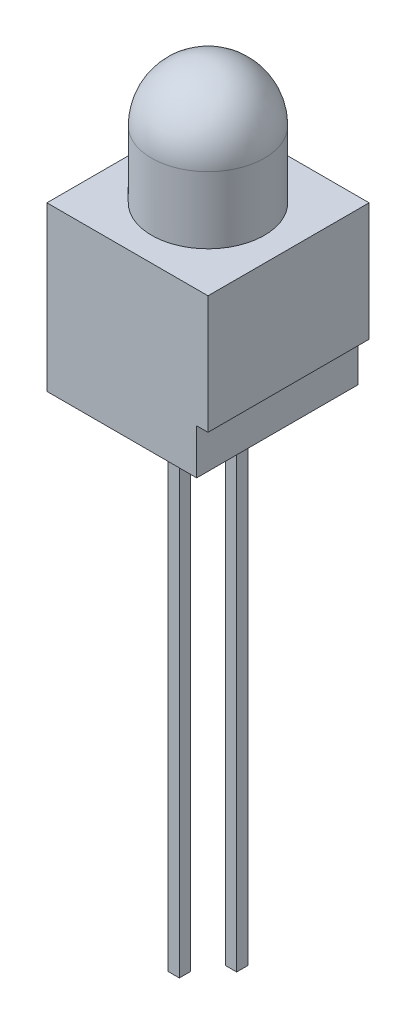
from build123d import *

# Parameters (mm, degrees)
EXTRUDE1_DEPTH     = 3.57
SKETCH1_5_W        = 0.5
SKETCH1_5_H        = 22.9
SKETCH1_5_H_2      = 21.4
EXTRUDE2_DEPTH     = 0.25
SKETCH2_W          = 0.025316456
SKETCH2_H          = 0.026582279
CUT_EXTRUDE1_DEPTH = 0.01


with BuildPart() as part:
    # Sketch1 → Extrude1 (new body, symmetric)
    with BuildSketch(Plane.XY):
        Polygon((0, 0), (-3.57, 0), (-3.57, -7.24), (-1.52, -7.24), (-1.02, -7.24), (1.02, -7.24), (1.52, -7.24), (3.07, -7.24), (3.07, -5.24), (3.57, -5.24), (3.57, 0), (2.5, 0), align=None)
    extrude(amount=EXTRUDE1_DEPTH, both=True)

    # Sketch1_4 → Revolve1 (revolve)
    with BuildSketch(Plane.XY, mode=Mode.PRIVATE) as revolve1_sk:
        with BuildLine():
            Line((0, 5.46), (0, 0))
            Line((0, 0), (2.5, 0))
            Line((2.5, 0), (2.5, 2.96))
            ThreePointArc((2.5, 2.96), (1.767766953, 4.727766953), (0, 5.46))
        make_face()
    revolve(revolve1_sk.sketch.rotate(Axis((0, 0, 0), (0, 1, 0)), 180), axis=Axis((0, 0, 0), (0, 1, 0)))  # turned: the seam where the file's is

    # Sketch1_5 → Extrude2 (add, symmetric)
    with BuildSketch(Plane.XY):
        with Locations((-1.27, -18.69)):
            Rectangle(SKETCH1_5_W, SKETCH1_5_H)
        with Locations((1.27, -17.94)):
            Rectangle(SKETCH1_5_W, SKETCH1_5_H_2)
    extrude(amount=EXTRUDE2_DEPTH, both=True)

    # Sketch2 → Cut-Extrude1 (cut)
    with BuildSketch(Plane.XZ.offset(7.24)):
        Polygon((-0.822151899, -2.422773337), (-0.845609177, -2.497456881), (-0.870352057, -2.497456881), (-0.886768196, -2.447120647), (-0.902294304, -2.497456881), (-0.928026108, -2.497456881), (-0.951265823, -2.422773337), (-0.926087816, -2.422773337), (-0.913093354, -2.474256723), (-0.896677215, -2.422773337), (-0.875178006, -2.422773337), (-0.858860759, -2.474256723), (-0.846044304, -2.422773337), align=None)
        Polygon((-0.687974684, -2.422773337), (-0.711431962, -2.497456881), (-0.736174842, -2.497456881), (-0.752590981, -2.447120647), (-0.768117089, -2.497456881), (-0.793848892, -2.497456881), (-0.817088608, -2.422773337), (-0.791910601, -2.422773337), (-0.778916139, -2.474256723), (-0.7625, -2.422773337), (-0.741000791, -2.422773337), (-0.724683544, -2.474256723), (-0.711867089, -2.422773337), align=None)
        Polygon((-0.553797468, -2.422773337), (-0.577254747, -2.497456881), (-0.601997627, -2.497456881), (-0.618413766, -2.447120647), (-0.633939873, -2.497456881), (-0.659671677, -2.497456881), (-0.682911392, -2.422773337), (-0.657733386, -2.422773337), (-0.644738924, -2.474256723), (-0.628322785, -2.422773337), (-0.606823576, -2.422773337), (-0.590506329, -2.474256723), (-0.577689873, -2.422773337), align=None)
        with Locations((-0.525949367, -2.484165742)):
            Rectangle(SKETCH2_W, SKETCH2_H)
        with BuildLine():
            add(Edge.make_bspline(
                [(-0.409493671, -2.466285995), (-0.40953016, -2.467508136), (-0.409601812, -2.469908014), (-0.41021153, -2.473415593), (-0.411205016, -2.476740298), (-0.412579134, -2.479902958), (-0.414367936, -2.482881577), (-0.416577526, -2.485661854), (-0.419141939, -2.488296654), (-0.422108149, -2.490702784), (-0.425388259, -2.492907161), (-0.428985835, -2.49480416), (-0.432864539, -2.496400643), (-0.437013125, -2.497739194), (-0.441459564, -2.498727775), (-0.446177094, -2.49945172), (-0.451170512, -2.49992505), (-0.45459409, -2.499967016), (-0.456348892, -2.499988527)],
                knots=[0, 0, 0, 0, 0.907352243, 1.781736951, 2.63548328, 3.47985091, 4.336556021, 5.208523475, 6.112432747, 7.062451073, 8.040435374, 9.043840564, 10.077958095, 11.152835584, 12.277940427, 13.457536469, 14.696825396, 16, 16, 16, 16], degree=3))
            add(Edge.make_bspline(
                [(-0.456348892, -2.499988527), (-0.458367148, -2.499964455), (-0.46227633, -2.49991783), (-0.467939855, -2.499489231), (-0.473207892, -2.498843092), (-0.478103607, -2.49787655), (-0.482708206, -2.496675785), (-0.487141474, -2.495384493), (-0.491422786, -2.493920078), (-0.494195876, -2.49281992), (-0.49556962, -2.492274919)],
                knots=[0, 0, 0, 0, 1.203215828, 2.33052265, 3.384689099, 4.366106119, 5.303329643, 6.221311756, 7.118865988, 8, 8, 8, 8], degree=3))
            Line((-0.49556962, -2.492274919), (-0.49556962, -2.468342957))
            Line((-0.49556962, -2.468342957), (-0.492721519, -2.468342957))
            add(Edge.make_bspline(
                [(-0.492721519, -2.468342957), (-0.491356205, -2.469424412), (-0.488633592, -2.471580973), (-0.484200359, -2.474343578), (-0.479552713, -2.476745741), (-0.474707243, -2.478719743), (-0.469810398, -2.480306067), (-0.46493502, -2.481399594), (-0.460169433, -2.482146943), (-0.457010864, -2.48222745), (-0.455458861, -2.482267008)],
                knots=[0, 0, 0, 0, 1.030622468, 2.055194264, 3.087043286, 4.125157485, 5.149848264, 6.130935704, 7.081611712, 8, 8, 8, 8], degree=3))
            add(Edge.make_bspline(
                [(-0.455458861, -2.482267008), (-0.455030085, -2.482266084), (-0.454112108, -2.482264107), (-0.452650581, -2.482136379), (-0.45099877, -2.482040803), (-0.449226261, -2.481833619), (-0.447429535, -2.481611758), (-0.445767134, -2.481236833), (-0.444257539, -2.480871966), (-0.443351018, -2.480503968), (-0.442919304, -2.480328716)],
                knots=[0, 0, 0, 0, 0.806402781, 1.726445712, 2.758724871, 3.919014682, 5.083870887, 6.16165551, 7.124521387, 8, 8, 8, 8], degree=3))
            add(Edge.make_bspline(
                [(-0.442919304, -2.480328716), (-0.442439741, -2.480100575), (-0.441497298, -2.479652227), (-0.440203698, -2.478841909), (-0.439036018, -2.477958444), (-0.437978647, -2.476993513), (-0.437104366, -2.475827763), (-0.436480499, -2.47441909), (-0.436135606, -2.472770072), (-0.436096583, -2.471594869), (-0.436075949, -2.470973495)],
                knots=[0, 0, 0, 0, 1.024747072, 2.013846092, 2.940605744, 3.850156746, 4.769278501, 5.73222711, 6.800942666, 8, 8, 8, 8], degree=3))
            add(Edge.make_bspline(
                [(-0.436075949, -2.470973495), (-0.436107794, -2.470427858), (-0.43617041, -2.469354974), (-0.436747603, -2.467819859), (-0.437657041, -2.466410691), (-0.438938631, -2.465141916), (-0.440531807, -2.463992383), (-0.442474191, -2.463010077), (-0.444724312, -2.46213689), (-0.446368382, -2.461718912), (-0.447231013, -2.461499602)],
                knots=[0, 0, 0, 0, 0.82557554, 1.623324704, 2.456147571, 3.35491006, 4.343819762, 5.427079081, 6.650009487, 8, 8, 8, 8], degree=3))
            add(Edge.make_bspline(
                [(-0.447231013, -2.461499602), (-0.449199639, -2.461051362), (-0.453238649, -2.460131712), (-0.459388473, -2.458992958), (-0.465516824, -2.457718098), (-0.469469591, -2.456511455), (-0.471400316, -2.455922071)],
                knots=[0, 0, 0, 0, 0.976100998, 2.002656142, 3.024398856, 4, 4, 4, 4], degree=3))
            add(Edge.make_bspline(
                [(-0.471400316, -2.455922071), (-0.472438835, -2.455569081), (-0.474460408, -2.454881953), (-0.477351919, -2.453720293), (-0.480013147, -2.452450463), (-0.48245286, -2.451094908), (-0.484653549, -2.449622368), (-0.486647817, -2.448080991), (-0.488410933, -2.446440951), (-0.489957738, -2.444701185), (-0.491282641, -2.442850482), (-0.492435025, -2.440905284), (-0.493417646, -2.438849865), (-0.494195684, -2.436679642), (-0.494820323, -2.434405986), (-0.495239305, -2.432028274), (-0.495538322, -2.429545145), (-0.495559046, -2.42785076), (-0.49556962, -2.426986153)],
                knots=[0, 0, 0, 0, 1.287047841, 2.5053592, 3.654260482, 4.74538952, 5.777514103, 6.75871007, 7.700244599, 8.599107454, 9.48590269, 10.366941872, 11.24940663, 12.154970331, 13.068988358, 14.012872203, 14.986013017, 16, 16, 16, 16], degree=3))
            add(Edge.make_bspline(
                [(-0.49556962, -2.426986153), (-0.495532318, -2.425830008), (-0.495458909, -2.423554736), (-0.49485748, -2.420225692), (-0.49383089, -2.417076955), (-0.492444827, -2.414073492), (-0.490616199, -2.411260406), (-0.488431404, -2.408581859), (-0.485807357, -2.406110267), (-0.482830235, -2.403809933), (-0.479542851, -2.401730535), (-0.476003867, -2.399899979), (-0.472234578, -2.398363327), (-0.468249032, -2.397089433), (-0.464030563, -2.396134762), (-0.45959333, -2.395415831), (-0.454919541, -2.395002649), (-0.45172812, -2.394951399), (-0.450098892, -2.394925235)],
                knots=[0, 0, 0, 0, 0.894990994, 1.761326291, 2.609044902, 3.454222546, 4.315366365, 5.200560057, 6.125081389, 7.100429509, 8.110379559, 9.133447974, 10.182136699, 11.259192205, 12.370181258, 13.528580438, 14.738335141, 16, 16, 16, 16], degree=3))
            add(Edge.make_bspline(
                [(-0.450098892, -2.394925235), (-0.448430198, -2.394947388), (-0.44509564, -2.394991656), (-0.4401143, -2.395370213), (-0.435159872, -2.395922525), (-0.430297448, -2.396771765), (-0.425605285, -2.397739997), (-0.42118617, -2.39883927), (-0.417106618, -2.400076777), (-0.414532965, -2.401031178), (-0.413291139, -2.401491691)],
                knots=[0, 0, 0, 0, 1.065407564, 2.129008667, 3.188544425, 4.247469455, 5.279542408, 6.247502114, 7.154394069, 8, 8, 8, 8], degree=3))
            Line((-0.413291139, -2.401491691), (-0.413291139, -2.424039159))
            Line((-0.413291139, -2.424039159), (-0.416119462, -2.424039159))
            add(Edge.make_bspline(
                [(-0.416119462, -2.424039159), (-0.417192966, -2.423239872), (-0.419383743, -2.421608706), (-0.423033347, -2.419506971), (-0.427000967, -2.417566879), (-0.431282594, -2.415875222), (-0.435742374, -2.414417215), (-0.440325133, -2.413397657), (-0.444951348, -2.41275595), (-0.448053052, -2.412683161), (-0.44960443, -2.412646754)],
                knots=[0, 0, 0, 0, 0.892265782, 1.820912499, 2.804518821, 3.836954028, 4.889985052, 5.931488012, 6.965393252, 8, 8, 8, 8], degree=3))
            add(Edge.make_bspline(
                [(-0.44960443, -2.412646754), (-0.450700035, -2.412668657), (-0.452897679, -2.412712591), (-0.45616687, -2.413097477), (-0.459407348, -2.413736329), (-0.46144203, -2.414552381), (-0.462460443, -2.414960837)],
                knots=[0, 0, 0, 0, 0.999122297, 2.004111588, 3.001004448, 4, 4, 4, 4], degree=3))
            add(Edge.make_bspline(
                [(-0.462460443, -2.414960837), (-0.462894173, -2.415162016), (-0.463761342, -2.415564239), (-0.464968884, -2.416343865), (-0.466089856, -2.417260208), (-0.467085439, -2.418312965), (-0.467929873, -2.419481319), (-0.468548899, -2.420748902), (-0.468923392, -2.422112783), (-0.468965739, -2.423047882), (-0.468987342, -2.423524919)],
                knots=[0, 0, 0, 0, 1.004925302, 2.009180302, 3.014392739, 4.04465309, 5.049195417, 6.035570224, 6.99785458, 8, 8, 8, 8], degree=3))
            add(Edge.make_bspline(
                [(-0.468987342, -2.423524919), (-0.468952904, -2.424163084), (-0.468887095, -2.42538256), (-0.468280511, -2.427098356), (-0.467295678, -2.42857679), (-0.466135073, -2.42957171), (-0.465017943, -2.430269148), (-0.463982284, -2.430779658), (-0.462773057, -2.431263017), (-0.461401809, -2.431760486), (-0.459865482, -2.432251673), (-0.458156925, -2.43272722), (-0.456274208, -2.433176516), (-0.454958333, -2.433462706), (-0.454272152, -2.433611944)],
                knots=[0, 0, 0, 0, 1.173816843, 2.243057204, 3.312297565, 4.415174738, 5.03266065, 5.73970059, 6.541434878, 7.433956553, 8.430083051, 9.515931566, 10.70464786, 12, 12, 12, 12], degree=3))
            add(Edge.make_bspline(
                [(-0.454272152, -2.433611944), (-0.452439229, -2.433987389), (-0.448844263, -2.43472376), (-0.443445039, -2.435836125), (-0.437940051, -2.437101484), (-0.434268899, -2.43825348), (-0.432357595, -2.438853242)],
                knots=[0, 0, 0, 0, 0.995749986, 1.952994291, 2.934271555, 4, 4, 4, 4], degree=3))
            add(Edge.make_bspline(
                [(-0.432357595, -2.438853242), (-0.431411107, -2.439172601), (-0.429559623, -2.439797318), (-0.426918075, -2.440882002), (-0.424469022, -2.442064092), (-0.422190751, -2.443286578), (-0.42012867, -2.444649794), (-0.418235447, -2.446064442), (-0.416552428, -2.44759255), (-0.415054478, -2.449205409), (-0.413736077, -2.450915841), (-0.412601114, -2.452753943), (-0.411637968, -2.454708472), (-0.410829836, -2.456781544), (-0.41025182, -2.458988612), (-0.409817762, -2.461314913), (-0.40952694, -2.463760228), (-0.409504884, -2.465434675), (-0.409493671, -2.466285995)],
                knots=[0, 0, 0, 0, 1.237386967, 2.420528625, 3.534815053, 4.605870898, 5.620827102, 6.594482803, 7.531295079, 8.432978826, 9.318460435, 10.202471551, 11.10474705, 12.014900263, 12.954095338, 13.926516828, 14.945802342, 16, 16, 16, 16], degree=3))
        make_face()
        with BuildLine():
            Line((-0.317088608, -2.497456881), (-0.341139241, -2.497456881))
            Line((-0.341139241, -2.497456881), (-0.341139241, -2.489624602))
            add(Edge.make_bspline(
                [(-0.341139241, -2.489624602), (-0.342232496, -2.49043327), (-0.344340276, -2.491992368), (-0.347514015, -2.494071133), (-0.350542736, -2.495854295), (-0.353464337, -2.497396447), (-0.356479693, -2.498587295), (-0.359707195, -2.499409151), (-0.363209459, -2.49991027), (-0.365636434, -2.499961862), (-0.366890823, -2.499988527)],
                knots=[0, 0, 0, 0, 1.150906677, 2.218931226, 3.20955724, 4.125565256, 5.012676028, 5.946647191, 6.938718366, 8, 8, 8, 8], degree=3))
            add(Edge.make_bspline(
                [(-0.366890823, -2.499988527), (-0.367907168, -2.499965797), (-0.369886286, -2.499921537), (-0.372763616, -2.4995768), (-0.375470927, -2.499038653), (-0.377987077, -2.498232797), (-0.380352422, -2.497258681), (-0.382503941, -2.495999593), (-0.38449163, -2.494540256), (-0.386295007, -2.492863321), (-0.387885627, -2.490942359), (-0.389272677, -2.488819608), (-0.390448489, -2.486484969), (-0.391390127, -2.483933603), (-0.392145061, -2.481175158), (-0.392669038, -2.478195952), (-0.392989618, -2.475008812), (-0.393021559, -2.472813684), (-0.393037975, -2.47168552)],
                knots=[0, 0, 0, 0, 1.108935798, 2.159418225, 3.158520219, 4.116592843, 5.038730546, 5.944611115, 6.829677354, 7.725673622, 8.624842385, 9.544872214, 10.487719724, 11.471363217, 12.50822837, 13.604887271, 14.769056852, 16, 16, 16, 16], degree=3))
            Line((-0.393037975, -2.47168552), (-0.393037975, -2.422773337))
            Line((-0.393037975, -2.422773337), (-0.368987342, -2.422773337))
            Line((-0.368987342, -2.422773337), (-0.368987342, -2.460352451))
            add(Edge.make_bspline(
                [(-0.368987342, -2.460352451), (-0.368985706, -2.461268922), (-0.368982576, -2.463023137), (-0.368900237, -2.465528944), (-0.368779336, -2.467797116), (-0.368640631, -2.469839145), (-0.368387615, -2.471685896), (-0.368009906, -2.473352057), (-0.36753908, -2.474871659), (-0.367074761, -2.47577836), (-0.366851266, -2.476214792)],
                knots=[0, 0, 0, 0, 1.361401701, 2.605856924, 3.723918663, 4.735739235, 5.645738665, 6.489217889, 7.27279937, 8, 8, 8, 8], degree=3))
            add(Edge.make_bspline(
                [(-0.366851266, -2.476214792), (-0.366621226, -2.47661344), (-0.366168987, -2.477397147), (-0.365249176, -2.478404295), (-0.364173193, -2.479241202), (-0.362903555, -2.479913846), (-0.361410474, -2.480397549), (-0.359678473, -2.480744296), (-0.357692458, -2.48095812), (-0.356283538, -2.480986282), (-0.355537975, -2.481001185)],
                knots=[0, 0, 0, 0, 0.849057291, 1.669173542, 2.503217716, 3.359509317, 4.311793648, 5.394940091, 6.621469141, 8, 8, 8, 8], degree=3))
            add(Edge.make_bspline(
                [(-0.355537975, -2.481001185), (-0.35499671, -2.480983727), (-0.353883832, -2.480947834), (-0.352178621, -2.480717905), (-0.350389592, -2.480356249), (-0.347875395, -2.479697226), (-0.34469925, -2.478518047), (-0.342335111, -2.477159245), (-0.341139241, -2.476471913)],
                knots=[0, 0, 0, 0, 0.638164724, 1.312110757, 2.025558264, 2.789159289, 4.375836335, 6, 6, 6, 6], degree=3))
            Line((-0.341139241, -2.476471913), (-0.341139241, -2.422773337))
            Line((-0.341139241, -2.422773337), (-0.317088608, -2.422773337))
            Line((-0.317088608, -2.422773337), (-0.317088608, -2.497456881))
        make_face()
        with BuildLine():
            Line((-0.219620253, -2.497456881), (-0.243670886, -2.497456881))
            Line((-0.243670886, -2.497456881), (-0.243670886, -2.459877767))
            add(Edge.make_bspline(
                [(-0.243670886, -2.459877767), (-0.24369121, -2.458347294), (-0.243731745, -2.455294881), (-0.244065325, -2.451538106), (-0.244399034, -2.448690315), (-0.244775857, -2.446854248), (-0.245206044, -2.445305912), (-0.24561849, -2.444420175), (-0.245806962, -2.444015425)],
                knots=[0, 0, 0, 0, 1.709235885, 3.408940626, 4.211008593, 4.910095588, 5.501954032, 6, 6, 6, 6], degree=3))
            add(Edge.make_bspline(
                [(-0.245806962, -2.444015425), (-0.24605139, -2.443617303), (-0.246530627, -2.442836728), (-0.247468442, -2.441824706), (-0.248565091, -2.440988492), (-0.249843815, -2.440323542), (-0.251328468, -2.439837644), (-0.253041142, -2.439450985), (-0.255027113, -2.439282425), (-0.256434481, -2.439247515), (-0.257179589, -2.439229033)],
                knots=[0, 0, 0, 0, 0.860145871, 1.686437142, 2.528070002, 3.393017362, 4.331453407, 5.402595683, 6.624848233, 8, 8, 8, 8], degree=3))
            add(Edge.make_bspline(
                [(-0.257179589, -2.439229033), (-0.258311478, -2.439285613), (-0.260622712, -2.439401146), (-0.263484003, -2.440114738), (-0.265810878, -2.440927035), (-0.267656499, -2.441701272), (-0.269573028, -2.442655897), (-0.270856452, -2.443382971), (-0.271518987, -2.443758305)],
                knots=[0, 0, 0, 0, 1.338419466, 2.732951426, 3.468143565, 4.254837763, 5.099104234, 6, 6, 6, 6], degree=3))
            Line((-0.271518987, -2.443758305), (-0.271518987, -2.497456881))
            Line((-0.271518987, -2.497456881), (-0.29556962, -2.497456881))
            Line((-0.29556962, -2.497456881), (-0.29556962, -2.422773337))
            Line((-0.29556962, -2.422773337), (-0.271518987, -2.422773337))
            Line((-0.271518987, -2.422773337), (-0.271518987, -2.430605615))
            add(Edge.make_bspline(
                [(-0.271518987, -2.430605615), (-0.27046175, -2.429799177), (-0.268403774, -2.428229398), (-0.265227022, -2.426195989), (-0.26215631, -2.424386132), (-0.259101788, -2.422873998), (-0.255977291, -2.421675398), (-0.25270966, -2.420859795), (-0.249292947, -2.420316847), (-0.246956274, -2.420267035), (-0.245767405, -2.420241691)],
                knots=[0, 0, 0, 0, 1.126064518, 2.191951536, 3.19307265, 4.144813015, 5.076393104, 6.021983703, 6.993610568, 8, 8, 8, 8], degree=3))
            add(Edge.make_bspline(
                [(-0.245767405, -2.420241691), (-0.244771134, -2.42026708), (-0.242826235, -2.420316644), (-0.239991474, -2.420626354), (-0.237320053, -2.421177018), (-0.234827778, -2.421974847), (-0.232485162, -2.42296046), (-0.230323205, -2.424191971), (-0.228331179, -2.42565041), (-0.22650261, -2.427311352), (-0.224872429, -2.42920131), (-0.223452943, -2.431317683), (-0.22228152, -2.433666411), (-0.221272688, -2.436213548), (-0.220538463, -2.438991318), (-0.220012012, -2.441982084), (-0.219661582, -2.445187266), (-0.219634305, -2.447403166), (-0.219620253, -2.448544697)],
                knots=[0, 0, 0, 0, 1.088441561, 2.124831547, 3.110816719, 4.062969431, 4.979391633, 5.88258537, 6.774334107, 7.671621258, 8.575503974, 9.49441354, 10.447872957, 11.437639084, 12.482478955, 13.580222388, 14.753440527, 16, 16, 16, 16], degree=3))
            Line((-0.219620253, -2.448544697), (-0.219620253, -2.497456881))
        make_face()
        Polygon((-0.124683544, -2.497456881), (-0.196835443, -2.497456881), (-0.196835443, -2.397456881), (-0.171518987, -2.397456881), (-0.171518987, -2.478469539), (-0.124683544, -2.478469539), align=None)
        Polygon((-0.037341772, -2.497456881), (-0.109493671, -2.497456881), (-0.109493671, -2.397456881), (-0.037341772, -2.397456881), (-0.037341772, -2.416444223), (-0.084177215, -2.416444223), (-0.084177215, -2.434165742), (-0.041139241, -2.434165742), (-0.041139241, -2.453153084), (-0.084177215, -2.453153084), (-0.084177215, -2.478469539), (-0.037341772, -2.478469539), align=None)
        with BuildLine():
            add(Edge.make_bspline(
                [(0.079113924, -2.447555773), (0.079094609, -2.448703462), (0.079056357, -2.450976348), (0.078761165, -2.454341155), (0.07823514, -2.45760683), (0.077555959, -2.460791079), (0.076633453, -2.463870007), (0.075551739, -2.466877584), (0.074242093, -2.469783077), (0.072737241, -2.472584512), (0.071087768, -2.475256615), (0.069313019, -2.477776823), (0.06746724, -2.480160041), (0.065477927, -2.482354935), (0.063398746, -2.484396955), (0.061223217, -2.486287769), (0.058918153, -2.4879912), (0.05731099, -2.489014084), (0.05650712, -2.48952571)],
                knots=[0, 0, 0, 0, 1.105570398, 2.18947457, 3.250358341, 4.290584537, 5.323553275, 6.344225964, 7.367641686, 8.3905646, 9.405808457, 10.390761353, 11.358902336, 12.307789878, 13.241960776, 14.165076779, 15.082208636, 16, 16, 16, 16], degree=3))
            add(Edge.make_bspline(
                [(0.05650712, -2.48952571), (0.055267899, -2.49023788), (0.052783134, -2.491665853), (0.048799188, -2.493333984), (0.044668069, -2.494741941), (0.040309515, -2.49579013), (0.035663167, -2.496518863), (0.03066851, -2.497081914), (0.025267382, -2.497382278), (0.0215325, -2.497431447), (0.019600475, -2.497456881)],
                knots=[0, 0, 0, 0, 0.896298978, 1.797171328, 2.70531317, 3.633678302, 4.606491125, 5.655688921, 6.787306437, 8, 8, 8, 8], degree=3))
            Line((0.019600475, -2.497456881), (-0.015822785, -2.497456881))
            Line((-0.015822785, -2.497456881), (-0.015822785, -2.397456881))
            Line((-0.015822785, -2.397456881), (0.020609177, -2.397456881))
            add(Edge.make_bspline(
                [(0.020609177, -2.397456881), (0.022587901, -2.397473576), (0.026404614, -2.39750578), (0.031915032, -2.397921748), (0.037013411, -2.398521268), (0.041697991, -2.39944796), (0.046006397, -2.400556611), (0.049937419, -2.401919647), (0.053549308, -2.403417919), (0.055728136, -2.404691666), (0.056784019, -2.405308938)],
                knots=[0, 0, 0, 0, 1.267192274, 2.444256634, 3.537982003, 4.553396635, 5.500903572, 6.385021601, 7.217363933, 8, 8, 8, 8], degree=3))
            add(Edge.make_bspline(
                [(0.056784019, -2.405308938), (0.057634972, -2.405845479), (0.059327097, -2.406912392), (0.061728312, -2.408694244), (0.063957739, -2.410650321), (0.066086242, -2.41270214), (0.068066056, -2.414905028), (0.069909269, -2.417243731), (0.071613036, -2.419721838), (0.073171192, -2.422331258), (0.074591277, -2.425061498), (0.075783356, -2.427933843), (0.076822718, -2.430916716), (0.077668801, -2.434015656), (0.07832513, -2.437233045), (0.078771214, -2.440570526), (0.079054647, -2.444023714), (0.079093999, -2.446368508), (0.079113924, -2.447555773)],
                knots=[0, 0, 0, 0, 0.964043478, 1.917004671, 2.862223898, 3.805158963, 4.749279098, 5.698713747, 6.657523689, 7.629652222, 8.610369353, 9.604453025, 10.607693792, 11.636365947, 12.681120053, 13.752669011, 14.862083412, 16, 16, 16, 16], degree=3))
        make_face()
        with BuildLine():
            add(Edge.make_bspline(
                [(0.052531646, -2.447397546), (0.052521175, -2.446592832), (0.052500636, -2.44501434), (0.052312313, -2.442698165), (0.052041725, -2.440472115), (0.051652591, -2.438328482), (0.051112159, -2.436278335), (0.050479977, -2.434316765), (0.049752887, -2.432437842), (0.048871957, -2.430660183), (0.047898133, -2.428951845), (0.046750689, -2.427366318), (0.045502338, -2.425853435), (0.044124055, -2.42442545), (0.042581114, -2.423119554), (0.040921012, -2.421889478), (0.039120654, -2.420761152), (0.037847665, -2.420101102), (0.037203323, -2.419767008)],
                knots=[0, 0, 0, 0, 1.152052275, 2.259818351, 3.325348653, 4.362224493, 5.376551665, 6.358740615, 7.312387502, 8.258104984, 9.197203025, 10.124507262, 11.056413058, 12.004389423, 12.961766972, 13.947352551, 14.961020569, 16, 16, 16, 16], degree=3))
            add(Edge.make_bspline(
                [(0.037203323, -2.419767008), (0.036528425, -2.419460296), (0.035190731, -2.418852371), (0.033119908, -2.418121179), (0.031030524, -2.417548343), (0.028828925, -2.417117485), (0.026359165, -2.416795554), (0.023433583, -2.416598295), (0.019977674, -2.416456126), (0.017490959, -2.416448375), (0.016159019, -2.416444223)],
                knots=[0, 0, 0, 0, 0.826967603, 1.639107464, 2.447640171, 3.242670507, 4.14065217, 5.225198036, 6.513753944, 8, 8, 8, 8], degree=3))
            Line((0.016159019, -2.416444223), (0.009493671, -2.416444223))
            Line((0.009493671, -2.416444223), (0.009493671, -2.478469539))
            Line((0.009493671, -2.478469539), (0.016159019, -2.478469539))
            add(Edge.make_bspline(
                [(0.016159019, -2.478469539), (0.016917226, -2.478464793), (0.018380993, -2.478455631), (0.02049723, -2.478412518), (0.022463046, -2.478365804), (0.024267852, -2.478248766), (0.025920195, -2.478178267), (0.027406342, -2.477994596), (0.028743292, -2.477860121), (0.030315773, -2.477582398), (0.03217096, -2.477176423), (0.034337749, -2.476493265), (0.036478448, -2.475643691), (0.037866999, -2.474958612), (0.038568038, -2.474612735)],
                knots=[0, 0, 0, 0, 1.186805873, 2.291202465, 3.313317863, 4.264127762, 5.122212376, 5.900577546, 6.607154111, 7.224697658, 8.398873738, 9.57716935, 10.776782771, 12, 12, 12, 12], degree=3))
            add(Edge.make_bspline(
                [(0.038568038, -2.474612735), (0.039153152, -2.474271218), (0.040307072, -2.4735977), (0.041930612, -2.472463649), (0.043438202, -2.471255839), (0.044834679, -2.469967699), (0.046096265, -2.468578313), (0.047252353, -2.467118847), (0.04825774, -2.465558526), (0.049496994, -2.4633697), (0.050744084, -2.460344943), (0.051776483, -2.456372189), (0.052415631, -2.452013277), (0.052491983, -2.448975536), (0.052531646, -2.447397546)],
                knots=[0, 0, 0, 0, 0.755237594, 1.489427721, 2.205882609, 2.908165467, 3.605466573, 4.296695275, 4.981837198, 5.673065901, 7.099889822, 8.61390339, 10.241051878, 12, 12, 12, 12], degree=3))
        make_face(mode=Mode.SUBTRACT)
        with Locations((0.110759494, -2.484165742)):
            Rectangle(SKETCH2_W, SKETCH2_H)
        with BuildLine():
            add(Edge.make_bspline(
                [(0.185403481, -2.499988527), (0.183813364, -2.499966723), (0.18069222, -2.499923927), (0.176120933, -2.499446899), (0.171755567, -2.498729602), (0.167609943, -2.497707283), (0.1636994, -2.496366764), (0.16004445, -2.494696758), (0.156627778, -2.492729562), (0.154565858, -2.491144666), (0.153540348, -2.490356406)],
                knots=[0, 0, 0, 0, 1.123701398, 2.205645569, 3.245398653, 4.249180969, 5.220497262, 6.163202923, 7.086456062, 8, 8, 8, 8], degree=3))
            add(Edge.make_bspline(
                [(0.153540348, -2.490356406), (0.152588713, -2.489501573), (0.150689124, -2.487795213), (0.148221497, -2.484824669), (0.146103421, -2.481535696), (0.144291165, -2.477944044), (0.142859214, -2.474024158), (0.141866679, -2.469774264), (0.141239075, -2.465216934), (0.141173123, -2.46206873), (0.141139241, -2.460451343)],
                knots=[0, 0, 0, 0, 0.916342154, 1.829140869, 2.758848968, 3.716597128, 4.708179637, 5.743612459, 6.840783343, 8, 8, 8, 8], degree=3))
            add(Edge.make_bspline(
                [(0.141139241, -2.460451343), (0.141178001, -2.458748116), (0.141253124, -2.455447036), (0.141916883, -2.450674848), (0.142986496, -2.446257168), (0.144524054, -2.442205259), (0.146454496, -2.438512068), (0.148718989, -2.435140233), (0.151339514, -2.432097309), (0.153346653, -2.430351869), (0.154351266, -2.429478242)],
                knots=[0, 0, 0, 0, 1.171797512, 2.271099083, 3.308930235, 4.294129479, 5.24602549, 6.17106565, 7.084581485, 8, 8, 8, 8], degree=3))
            add(Edge.make_bspline(
                [(0.154351266, -2.429478242), (0.15537705, -2.428709463), (0.157441008, -2.42716262), (0.160840547, -2.425267807), (0.16445276, -2.42366329), (0.168283877, -2.422417404), (0.172264395, -2.421468867), (0.176329936, -2.420741895), (0.180476303, -2.42032187), (0.183266488, -2.420268546), (0.184671677, -2.420241691)],
                knots=[0, 0, 0, 0, 0.952097844, 1.915695341, 2.885641886, 3.886921822, 4.905719434, 5.925883802, 6.95543633, 8, 8, 8, 8], degree=3))
            add(Edge.make_bspline(
                [(0.184671677, -2.420241691), (0.185918404, -2.420258655), (0.188369891, -2.420292011), (0.191970824, -2.420614668), (0.195419409, -2.421144833), (0.198716721, -2.421888427), (0.201889869, -2.422781226), (0.204949341, -2.423812506), (0.207914157, -2.424950447), (0.209814835, -2.425834663), (0.210759494, -2.426274128)],
                knots=[0, 0, 0, 0, 1.107671842, 2.178058178, 3.209662749, 4.206063564, 5.179815947, 6.137646632, 7.07438927, 8, 8, 8, 8], degree=3))
            Line((0.210759494, -2.426274128), (0.210759494, -2.44682397))
            Line((0.210759494, -2.44682397), (0.20741693, -2.44682397))
            add(Edge.make_bspline(
                [(0.20741693, -2.44682397), (0.206918162, -2.446405743), (0.205836226, -2.445498519), (0.204034874, -2.444097506), (0.201901363, -2.44254694), (0.200250156, -2.441660937), (0.199367089, -2.441187102)],
                knots=[0, 0, 0, 0, 0.792878214, 1.719922066, 2.780612869, 4, 4, 4, 4], degree=3))
            add(Edge.make_bspline(
                [(0.199367089, -2.441187102), (0.198439429, -2.440744234), (0.1965324, -2.439833811), (0.193972423, -2.439014267), (0.191783392, -2.43843573), (0.189971509, -2.438182921), (0.188038089, -2.437992572), (0.186702818, -2.437973177), (0.186016614, -2.43796321)],
                knots=[0, 0, 0, 0, 1.33256682, 2.739414054, 3.480190821, 4.267897792, 5.109861573, 6, 6, 6, 6], degree=3))
            add(Edge.make_bspline(
                [(0.186016614, -2.43796321), (0.185251065, -2.437982769), (0.183767468, -2.438020675), (0.181605865, -2.438297597), (0.179587789, -2.438776332), (0.177683381, -2.439414743), (0.175944635, -2.440310983), (0.174302105, -2.441323251), (0.172827629, -2.442577758), (0.171485682, -2.443995499), (0.170298198, -2.445586012), (0.169271446, -2.4473125), (0.168388719, -2.449170393), (0.167686826, -2.451168301), (0.167129316, -2.453298163), (0.166739751, -2.455560973), (0.166497972, -2.457960571), (0.166470029, -2.459606866), (0.166455696, -2.460451343)],
                knots=[0, 0, 0, 0, 1.087094245, 2.106738054, 3.087824582, 4.029427112, 4.95060567, 5.859714611, 6.763601524, 7.690850518, 8.627131371, 9.576106403, 10.539384251, 11.543302637, 12.578856349, 13.662518017, 14.800975475, 16, 16, 16, 16], degree=3))
            add(Edge.make_bspline(
                [(0.166455696, -2.460451343), (0.166470471, -2.461315499), (0.166499177, -2.462994512), (0.166732691, -2.465436123), (0.167148582, -2.467717554), (0.16771983, -2.469842874), (0.168444178, -2.471808892), (0.169349295, -2.473606289), (0.170385652, -2.475263096), (0.17163021, -2.476725708), (0.172994093, -2.478042029), (0.174508985, -2.479178164), (0.176168224, -2.480126309), (0.177950405, -2.480930772), (0.179883445, -2.48150917), (0.181939982, -2.481945862), (0.184129537, -2.482234419), (0.185639891, -2.482255982), (0.186412184, -2.482267008)],
                knots=[0, 0, 0, 0, 1.230336593, 2.390482092, 3.487897344, 4.52859895, 5.520747884, 6.465347575, 7.38981449, 8.296085817, 9.192433006, 10.084246191, 10.984321635, 11.908883871, 12.862027947, 13.850751296, 14.901019963, 16, 16, 16, 16], degree=3))
            add(Edge.make_bspline(
                [(0.186412184, -2.482267008), (0.187138026, -2.482258784), (0.188553028, -2.482242753), (0.190611451, -2.482026686), (0.192565368, -2.48174736), (0.194399915, -2.481306083), (0.196104164, -2.480771199), (0.197669817, -2.480200373), (0.199082423, -2.479596093), (0.199943758, -2.479128477), (0.200356013, -2.478904666)],
                knots=[0, 0, 0, 0, 1.200879421, 2.341068892, 3.423000803, 4.465923194, 5.460027553, 6.378409259, 7.223869634, 8, 8, 8, 8], degree=3))
            add(Edge.make_bspline(
                [(0.200356013, -2.478904666), (0.201064369, -2.47847698), (0.202425742, -2.477655021), (0.204250861, -2.476234561), (0.205894986, -2.474828121), (0.206919091, -2.473871353), (0.20741693, -2.473406248)],
                knots=[0, 0, 0, 0, 1.105932972, 2.12546697, 3.088749538, 4, 4, 4, 4], degree=3))
            Line((0.20741693, -2.473406248), (0.210759494, -2.473406248))
            Line((0.210759494, -2.473406248), (0.210759494, -2.494114318))
            add(Edge.make_bspline(
                [(0.210759494, -2.494114318), (0.209814117, -2.49455186), (0.207923136, -2.495427049), (0.205008359, -2.4965802), (0.202015116, -2.497553079), (0.198963886, -2.498445426), (0.195794254, -2.499143621), (0.192476905, -2.499632851), (0.188995601, -2.49993459), (0.186617185, -2.499970302), (0.185403481, -2.499988527)],
                knots=[0, 0, 0, 0, 0.952024047, 1.90427691, 2.862762905, 3.827874523, 4.80891974, 5.826446878, 6.890837857, 8, 8, 8, 8], degree=3))
        make_face()
        with BuildLine():
            add(Edge.make_bspline(
                [(0.303164557, -2.460154666), (0.303139637, -2.461659498), (0.303091062, -2.464592819), (0.302554854, -2.468865639), (0.301731391, -2.47289608), (0.300598066, -2.476696918), (0.299080213, -2.480239964), (0.297237799, -2.483535918), (0.295064208, -2.4865881), (0.292573889, -2.489378327), (0.289772404, -2.491876519), (0.286698638, -2.494072712), (0.283328772, -2.49587976), (0.279720026, -2.497406309), (0.275830719, -2.49856241), (0.271671624, -2.499380361), (0.267254115, -2.499914692), (0.264215749, -2.499963505), (0.262658228, -2.499988527)],
                knots=[0, 0, 0, 0, 1.120122129, 2.18341868, 3.201215738, 4.181270334, 5.131540819, 6.065757527, 6.988093576, 7.916512302, 8.844931028, 9.778115023, 10.722851943, 11.686686084, 12.691660064, 13.738321946, 14.84062285, 16, 16, 16, 16], degree=3))
            add(Edge.make_bspline(
                [(0.262658228, -2.499988527), (0.26110068, -2.499963587), (0.258062261, -2.499914935), (0.253645127, -2.499379465), (0.249490907, -2.498566747), (0.245606256, -2.497397512), (0.241991945, -2.495885422), (0.238618118, -2.49407198), (0.235543936, -2.491876727), (0.232742733, -2.489378217), (0.230251696, -2.486588332), (0.228080692, -2.483535102), (0.226229753, -2.48024531), (0.22474936, -2.476688035), (0.223576829, -2.472900827), (0.222764049, -2.468864829), (0.222224732, -2.464593038), (0.222176594, -2.461659572), (0.222151899, -2.460154666)],
                knots=[0, 0, 0, 0, 1.159424321, 2.261770074, 3.308474541, 4.308788811, 5.277191138, 6.221966496, 7.15518846, 8.08364496, 9.01210146, 9.934475036, 10.868729753, 11.817121636, 12.798654016, 13.816492484, 14.879832297, 16, 16, 16, 16], degree=3))
            add(Edge.make_bspline(
                [(0.222151899, -2.460154666), (0.222177022, -2.458643242), (0.222226107, -2.455690232), (0.222761477, -2.451391359), (0.223579494, -2.447330708), (0.224739526, -2.443522395), (0.226255799, -2.439970795), (0.228096824, -2.436668691), (0.230293292, -2.433622116), (0.23280279, -2.430832364), (0.235614584, -2.428335983), (0.238708516, -2.426163078), (0.242060435, -2.42432642), (0.245667634, -2.422804587), (0.24955419, -2.421670022), (0.253691132, -2.420852443), (0.258088526, -2.420314371), (0.261107264, -2.420266359), (0.262658228, -2.420241691)],
                knots=[0, 0, 0, 0, 1.124034801, 2.196132384, 3.217834281, 4.203147447, 5.152578239, 6.085969439, 7.010345409, 7.941219594, 8.872481455, 9.802010446, 10.748267785, 11.711250247, 12.709230373, 13.754967386, 14.846549946, 16, 16, 16, 16], degree=3))
            add(Edge.make_bspline(
                [(0.262658228, -2.420241691), (0.264228972, -2.420266403), (0.267287148, -2.420314517), (0.271730477, -2.420850856), (0.275904607, -2.421663382), (0.279802216, -2.422831452), (0.283426224, -2.424334721), (0.2867734, -2.426189668), (0.289858359, -2.428364018), (0.292626621, -2.430893846), (0.29511038, -2.4336888), (0.297272736, -2.43674648), (0.299108213, -2.440054056), (0.300583955, -2.443615931), (0.301758158, -2.447408563), (0.302578569, -2.45144299), (0.303084721, -2.455717897), (0.303137483, -2.45865004), (0.303164557, -2.460154666)],
                knots=[0, 0, 0, 0, 1.167473013, 2.273023816, 3.322954552, 4.326451713, 5.293391623, 6.234801871, 7.166614545, 8.093305908, 9.017100806, 9.942078766, 10.872536262, 11.824015763, 12.804065898, 13.820367293, 14.881523901, 16, 16, 16, 16], degree=3))
        make_face()
        with BuildLine():
            add(Edge.make_bspline(
                [(0.273457278, -2.478647546), (0.273812024, -2.478147352), (0.274533974, -2.4771294), (0.275409914, -2.475434208), (0.276169567, -2.473602941), (0.276788254, -2.471576658), (0.277298396, -2.46927888), (0.277600016, -2.466621949), (0.277832831, -2.463587063), (0.277842811, -2.461434255), (0.277848101, -2.460293115)],
                knots=[0, 0, 0, 0, 0.765094823, 1.557058493, 2.376706509, 3.238810155, 4.199844458, 5.312104478, 6.575226644, 8, 8, 8, 8], degree=3))
            add(Edge.make_bspline(
                [(0.277848101, -2.460293115), (0.277830412, -2.459218233), (0.277796522, -2.457158877), (0.277610152, -2.454199114), (0.277261478, -2.451515688), (0.2767636, -2.449098292), (0.276153829, -2.446927604), (0.275427894, -2.444985241), (0.274589376, -2.443266639), (0.273903909, -2.442261408), (0.273575949, -2.441780457)],
                knots=[0, 0, 0, 0, 1.337076348, 2.561692668, 3.686680134, 4.69989255, 5.629188848, 6.488203485, 7.276684665, 8, 8, 8, 8], degree=3))
            add(Edge.make_bspline(
                [(0.273575949, -2.441780457), (0.273237376, -2.44134262), (0.272576126, -2.440487503), (0.271418372, -2.439383869), (0.270137891, -2.438505919), (0.268757044, -2.437837254), (0.267316335, -2.437323745), (0.265810213, -2.436967703), (0.264253653, -2.43674654), (0.263192974, -2.436713862), (0.262658228, -2.436697387)],
                knots=[0, 0, 0, 0, 1.058499091, 2.067300666, 3.047512573, 4.018335651, 4.996351322, 5.969796037, 6.97646375, 8, 8, 8, 8], degree=3))
            add(Edge.make_bspline(
                [(0.262658228, -2.436697387), (0.262130325, -2.436708417), (0.261097766, -2.436729991), (0.259594689, -2.436908508), (0.258179036, -2.437208507), (0.25683387, -2.437612692), (0.255548722, -2.438224069), (0.254317445, -2.439072886), (0.253102058, -2.440149466), (0.25236373, -2.440999801), (0.251977848, -2.441444223)],
                knots=[0, 0, 0, 0, 1.04189444, 2.037910168, 2.982338511, 3.896140384, 4.804271323, 5.778885192, 6.839150358, 8, 8, 8, 8], degree=3))
            add(Edge.make_bspline(
                [(0.251977848, -2.441444223), (0.251642414, -2.44191789), (0.250938424, -2.442911998), (0.250089235, -2.444632368), (0.249319936, -2.446577859), (0.248640648, -2.448768995), (0.248109463, -2.451236534), (0.247751274, -2.453995148), (0.247506594, -2.457045082), (0.247481478, -2.459178389), (0.247468354, -2.460293115)],
                knots=[0, 0, 0, 0, 0.70629823, 1.482341141, 2.329662943, 3.254583898, 4.274063958, 5.401087491, 6.641978366, 8, 8, 8, 8], degree=3))
            add(Edge.make_bspline(
                [(0.247468354, -2.460293115), (0.247474295, -2.461295854), (0.2474858, -2.463237986), (0.247727995, -2.466040318), (0.248014823, -2.468648762), (0.248501392, -2.471036815), (0.24907323, -2.473221991), (0.249821274, -2.475173585), (0.250644614, -2.476928658), (0.251344968, -2.477956397), (0.251681171, -2.478449761)],
                knots=[0, 0, 0, 0, 1.270983191, 2.461674417, 3.564986371, 4.596265355, 5.549463796, 6.425202083, 7.244022889, 8, 8, 8, 8], degree=3))
            add(Edge.make_bspline(
                [(0.251681171, -2.478449761), (0.252021533, -2.478866536), (0.252692579, -2.479688233), (0.253840375, -2.480764374), (0.255108347, -2.481638931), (0.256457966, -2.482361921), (0.257924557, -2.482896304), (0.259484843, -2.483266237), (0.261142292, -2.483485376), (0.262275179, -2.483516747), (0.262856013, -2.48353283)],
                knots=[0, 0, 0, 0, 1.010886179, 1.993025998, 2.945391046, 3.898964935, 4.863589088, 5.87059323, 6.908247091, 8, 8, 8, 8], degree=3))
            add(Edge.make_bspline(
                [(0.262856013, -2.48353283), (0.263863641, -2.483480309), (0.265861448, -2.483376176), (0.268276869, -2.482659769), (0.270078527, -2.481804791), (0.271333325, -2.480945382), (0.272471635, -2.479884613), (0.273124499, -2.479065212), (0.273457278, -2.478647546)],
                knots=[0, 0, 0, 0, 1.49343762, 2.961012893, 3.700518105, 4.446788108, 5.208294864, 6, 6, 6, 6], degree=3))
        make_face(mode=Mode.SUBTRACT)
        with BuildLine():
            Line((0.394303797, -2.443758305), (0.394303797, -2.497456881))
            Line((0.394303797, -2.497456881), (0.370253165, -2.497456881))
            Line((0.370253165, -2.497456881), (0.370253165, -2.459600868))
            add(Edge.make_bspline(
                [(0.370253165, -2.459600868), (0.370246898, -2.458710869), (0.370234875, -2.457003304), (0.370212363, -2.454542974), (0.370096991, -2.452295632), (0.370000439, -2.450248296), (0.369801755, -2.448391911), (0.369524083, -2.446712202), (0.369095228, -2.445209206), (0.368687802, -2.444308091), (0.36849288, -2.443876976)],
                knots=[0, 0, 0, 0, 1.33997484, 2.570892857, 3.703483919, 4.727540125, 5.655929516, 6.512630168, 7.288405602, 8, 8, 8, 8], degree=3))
            add(Edge.make_bspline(
                [(0.36849288, -2.443876976), (0.368282954, -2.443491609), (0.36786683, -2.442727715), (0.366998785, -2.441759855), (0.365990476, -2.44094921), (0.364810314, -2.440307755), (0.363431631, -2.439809593), (0.361816509, -2.439460247), (0.359952652, -2.439279845), (0.358630364, -2.439246608), (0.357931171, -2.439229033)],
                knots=[0, 0, 0, 0, 0.859345536, 1.703436662, 2.532498256, 3.390183975, 4.328249457, 5.402602062, 6.626559876, 8, 8, 8, 8], degree=3))
            add(Edge.make_bspline(
                [(0.357931171, -2.439229033), (0.357343832, -2.439252428), (0.356163857, -2.43929943), (0.354399742, -2.439544372), (0.352672133, -2.440039754), (0.350453045, -2.440877466), (0.347854183, -2.442101658), (0.345886252, -2.44321912), (0.344936709, -2.443758305)],
                knots=[0, 0, 0, 0, 0.759382397, 1.525614786, 2.294447385, 3.076151307, 4.589219126, 6, 6, 6, 6], degree=3))
            Line((0.344936709, -2.443758305), (0.344936709, -2.497456881))
            Line((0.344936709, -2.497456881), (0.320886076, -2.497456881))
            Line((0.320886076, -2.497456881), (0.320886076, -2.422773337))
            Line((0.320886076, -2.422773337), (0.344936709, -2.422773337))
            Line((0.344936709, -2.422773337), (0.344936709, -2.430605615))
            add(Edge.make_bspline(
                [(0.344936709, -2.430605615), (0.345957797, -2.429824235), (0.347940337, -2.428307112), (0.350953613, -2.426259784), (0.353906507, -2.4245042), (0.356799194, -2.422956304), (0.359752873, -2.421716689), (0.362851277, -2.42087375), (0.366094567, -2.420342677), (0.368312774, -2.420275763), (0.369442247, -2.420241691)],
                knots=[0, 0, 0, 0, 1.136109262, 2.205863928, 3.217041414, 4.170849475, 5.103496751, 6.040664374, 7.002340634, 8, 8, 8, 8], degree=3))
            add(Edge.make_bspline(
                [(0.369442247, -2.420241691), (0.370645481, -2.420273445), (0.37299712, -2.420335506), (0.376409162, -2.421004646), (0.379624607, -2.422009714), (0.382582226, -2.423498533), (0.385302424, -2.425339985), (0.387715584, -2.427596724), (0.389805479, -2.430263967), (0.39089703, -2.432269194), (0.391455696, -2.433295489)],
                knots=[0, 0, 0, 0, 1.065971563, 2.0833675, 3.072814207, 4.045738768, 5.009267307, 5.977487593, 6.964858173, 8, 8, 8, 8], degree=3))
            add(Edge.make_bspline(
                [(0.391455696, -2.433295489), (0.392637781, -2.432318524), (0.394941436, -2.430414608), (0.398495052, -2.427871986), (0.401974132, -2.425617429), (0.405414652, -2.423708604), (0.408815096, -2.42215805), (0.412197602, -2.421064063), (0.415544031, -2.420371699), (0.417771115, -2.42028461), (0.418868671, -2.420241691)],
                knots=[0, 0, 0, 0, 1.188147474, 2.315470194, 3.384102413, 4.399459064, 5.362307068, 6.27522031, 7.149990929, 8, 8, 8, 8], degree=3))
            add(Edge.make_bspline(
                [(0.418868671, -2.420241691), (0.419851921, -2.420265086), (0.421765063, -2.420310606), (0.42454762, -2.420645621), (0.427143805, -2.421217351), (0.429562078, -2.422006281), (0.431795216, -2.423038588), (0.433841647, -2.4243149), (0.435714647, -2.4258007), (0.437386566, -2.427522363), (0.438872492, -2.429446495), (0.440168729, -2.431581462), (0.441246883, -2.433921546), (0.442144985, -2.436456055), (0.442829098, -2.439192238), (0.443319166, -2.442135154), (0.443617377, -2.445275084), (0.443652749, -2.447436433), (0.443670886, -2.448544697)],
                knots=[0, 0, 0, 0, 1.099528869, 2.139389204, 3.128691273, 4.06836032, 4.978849901, 5.872980696, 6.759662307, 7.646067956, 8.55014577, 9.473266406, 10.433198647, 11.426668526, 12.476415665, 13.583140093, 14.760718182, 16, 16, 16, 16], degree=3))
            Line((0.443670886, -2.448544697), (0.443670886, -2.497456881))
            Line((0.443670886, -2.497456881), (0.419620253, -2.497456881))
            Line((0.419620253, -2.497456881), (0.419620253, -2.459600868))
            add(Edge.make_bspline(
                [(0.419620253, -2.459600868), (0.419614543, -2.458704252), (0.419603583, -2.456983457), (0.419573902, -2.454517103), (0.419484266, -2.452269286), (0.419403721, -2.450229395), (0.4192351, -2.448377261), (0.418948066, -2.446705612), (0.418517939, -2.445213623), (0.418126047, -2.444308699), (0.417939082, -2.443876976)],
                knots=[0, 0, 0, 0, 1.350843832, 2.592553583, 3.715618503, 4.739861077, 5.667890227, 6.515410335, 7.291728161, 8, 8, 8, 8], degree=3))
            add(Edge.make_bspline(
                [(0.417939082, -2.443876976), (0.417735705, -2.443491971), (0.417333047, -2.442729715), (0.416483935, -2.441754723), (0.415472098, -2.440944195), (0.414275171, -2.440308543), (0.412877515, -2.439809651), (0.411242699, -2.439460486), (0.409352701, -2.43927919), (0.408010647, -2.439246425), (0.407298259, -2.439229033)],
                knots=[0, 0, 0, 0, 0.84645005, 1.675850114, 2.498752818, 3.361341904, 4.304511378, 5.383432037, 6.611077598, 8, 8, 8, 8], degree=3))
            add(Edge.make_bspline(
                [(0.407298259, -2.439229033), (0.406297666, -2.439277482), (0.40427854, -2.43937525), (0.401790256, -2.440078221), (0.399774065, -2.440907863), (0.398078326, -2.441681093), (0.396237567, -2.442651514), (0.394967402, -2.443378492), (0.394303797, -2.443758305)],
                knots=[0, 0, 0, 0, 1.291070249, 2.605286939, 3.312383926, 4.109045945, 5.012060117, 6, 6, 6, 6], degree=3))
        make_face()
    extrude(amount=-CUT_EXTRUDE1_DEPTH, mode=Mode.SUBTRACT)


solid = part.part
